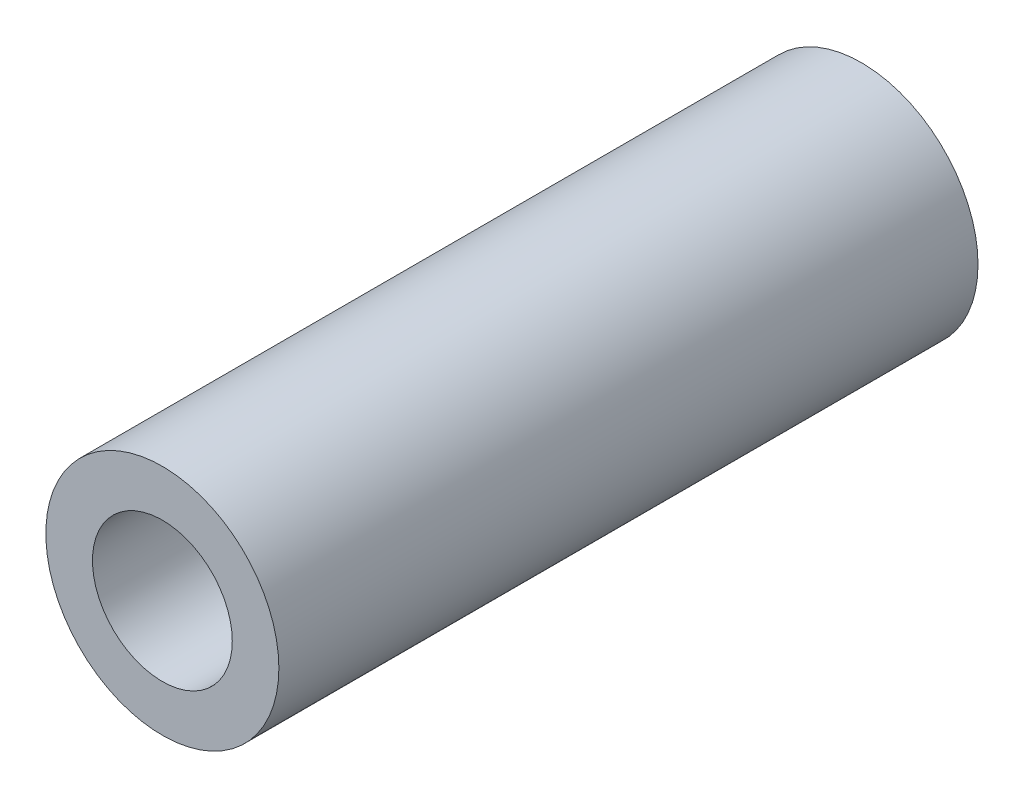
from build123d import *

# Parameters (mm, degrees)
SKETCH_1_R      = 2.5
SKETCH_1_R_2    = 1.5
EXTRUDE_1_DEPTH = 7.5


with BuildPart() as part:
    # 草图1 → 凸台-拉伸1 (new body, symmetric)
    with BuildSketch(Plane.XY):
        Circle(SKETCH_1_R)
        Circle(SKETCH_1_R_2, mode=Mode.SUBTRACT)
    extrude(amount=EXTRUDE_1_DEPTH, both=True)


solid = part.part
